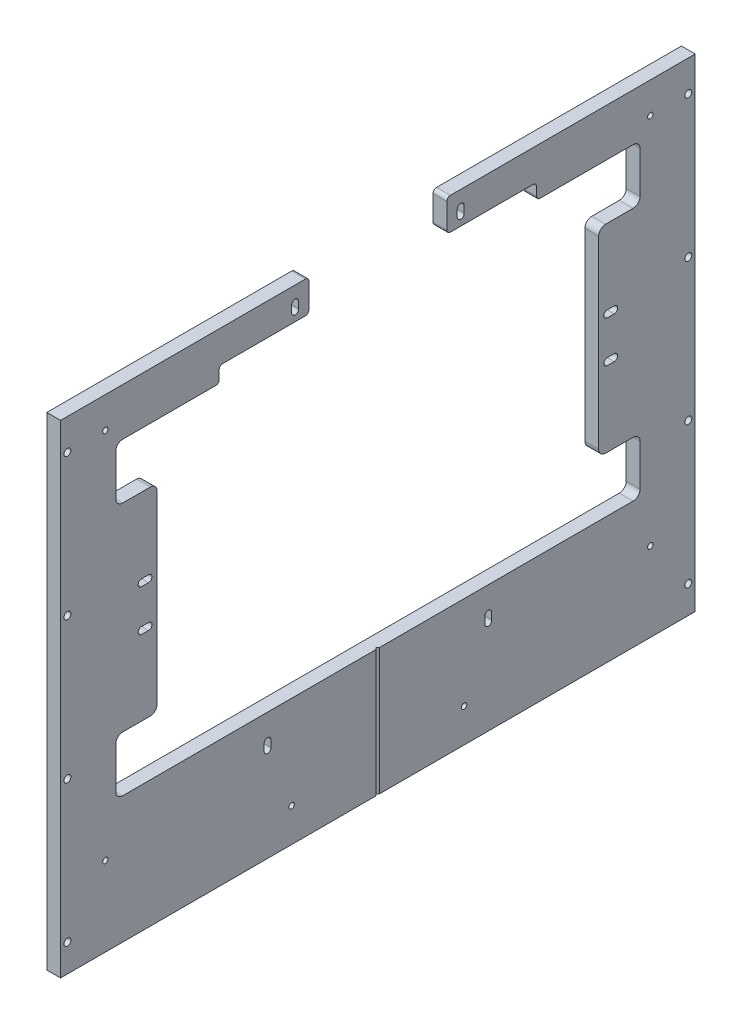
from build123d import *

# Parameters (mm, degrees)
SKETCH1_W                 = 12.7
SKETCH1_H                 = 444.5
EXTRUDE1_DEPTH            = 292.1
EXTRUDE1_DEPTH_BACK       = 292.1
CUT_EXTRUDE1_REACH        = 14.7
CUT_EXTRUDE2_REACH        = 14.7
SKETCH5_W                 = 127
SKETCH5_H                 = 43.65625
FILLET2_R                 = 6.35
M6X1_0_TAPPED_HOLE1_D     = 5
M6X1_0_TAPPED_HOLE1_DEPTH = 12.7
SKETCH11_W                = 292.1
SKETCH11_H                = 14.2875
CUT_EXTRUDE3_DEPTH        = 13.7
FILLET3_R                 = 3.175
CUT_EXTRUDE8_REACH        = 14.7
CUT_EXTRUDE7_DEPTH        = 1
CUT_EXTRUDE7_DEPTH_BACK   = 445.5
M6X1_0_TAPPED_HOLE2_D     = 5
M6X1_0_TAPPED_HOLE2_DEPTH = 12.7
M6_CLEARANCE_HOLE1_D      = 6.4
M6_CLEARANCE_HOLE1_DEPTH  = 12.7
M6X1_0_TAPPED_HOLE3_D     = 5
M6X1_0_TAPPED_HOLE3_DEPTH = 12.7
CUT_EXTRUDE9_DEPTH        = 13.7


with BuildPart() as part:
    # Sketch1 → Extrude1 (new body, two sides)
    with BuildSketch(Plane.XY) as extrude1_sk:
        Rectangle(SKETCH1_W, SKETCH1_H)
    extrude(amount=EXTRUDE1_DEPTH)
    extrude(extrude1_sk.sketch, amount=-EXTRUDE1_DEPTH_BACK)

    # Sketch4 → Cut-Extrude1 (cut, up to next)
    with BuildSketch(Plane(origin=(6.35, 0, 0), x_dir=(0, 0, -1), z_dir=(1, 0, 0)), mode=Mode.PRIVATE) as cut_extrude1_sk1:
        Polygon((203.2, 127.79375), (241.3, 127.79375), (241.3, 178.59375), (-241.3, 178.59375), (-241.3, 127.79375), (-203.2, 127.79375), (-203.2, -54.76875), (-241.3, -54.76875), (-241.3, -105.56875), (241.3, -105.56875), (241.3, -54.76875), (203.2, -54.76875), align=None)
    cut_extrude1_tool1 = extrude(cut_extrude1_sk1.sketch, amount=-CUT_EXTRUDE1_REACH, mode=Mode.PRIVATE) & part.part
    add(cut_extrude1_tool1.solids().sort_by_distance((6.35, 36.5125, 0))[0], mode=Mode.SUBTRACT)

    # Sketch5 → Cut-Extrude2 (cut, up to next)
    with BuildSketch(Plane(origin=(6.35, 0, 0), x_dir=(0, 0, -1), z_dir=(1, 0, 0)), mode=Mode.PRIVATE) as cut_extrude2_sk1:
        with Locations((0, 200.421875)):
            Rectangle(SKETCH5_W, SKETCH5_H)
    cut_extrude2_tool1 = extrude(cut_extrude2_sk1.sketch, amount=-CUT_EXTRUDE2_REACH, mode=Mode.PRIVATE) & part.part
    add(cut_extrude2_tool1.solids().sort_by_distance((6.35, 200.421875, 0))[0], mode=Mode.SUBTRACT)

    # Fillet2
    fillet2_edges = [part.edges().sort_by_distance(p)[0] for p in [
        (0, 127.79375, -203.2),
        (0, -54.76875, -203.2),
        (0, -54.76875, -241.3),
        (0, -105.56875, -241.3),
        (0, -105.56875, 241.3),
        (0, -54.76875, 241.3),
        (0, -54.76875, 203.2),
        (0, 127.79375, 203.2),
        (0, 127.79375, 241.3),
        (0, 178.59375, 241.3),
        (0, 178.59375, -241.3),
        (0, 127.79375, -241.3),
    ]]
    fillet(fillet2_edges, radius=FILLET2_R)

    # M6x1.0 Tapped Hole1
    with Locations(Plane(origin=(6.35, 0, 0), x_dir=(0, 0, -1), z_dir=(1, 0, 0))):
        with Locations((76.2, 204.7875), (-76.2, 204.7875), (101.6, -132.23875), (-101.6, -132.23875), (0, 204.7875)):
            Hole(M6X1_0_TAPPED_HOLE1_D / 2, depth=M6X1_0_TAPPED_HOLE1_DEPTH)

    # Sketch11 → Cut-Extrude3 (cut, through all)
    with BuildSketch(Plane(origin=(6.35, 0, 0), x_dir=(0, 0, -1), z_dir=(1, 0, 0))):
        with Locations((0, 185.7375)):
            Rectangle(SKETCH11_W, SKETCH11_H)
    extrude(amount=-CUT_EXTRUDE3_DEPTH, mode=Mode.SUBTRACT)

    # Fillet3
    fillet3_edges = [part.edges().sort_by_distance(p)[0] for p in [
        (0, 192.88125, 63.5),
        (0, 192.88125, -63.5),
        (0, 192.88125, 146.05),
        (0, 178.59375, -146.05),
        (0, 178.59375, 146.05),
        (0, 192.88125, -146.05),
        (0, 222.25, 63.5),
        (0, 222.25, -63.5),
    ]]
    fillet(fillet3_edges, radius=FILLET3_R)

    # Sketch19 → Cut-Extrude8 (cut, up to next)
    with BuildSketch(Plane(origin=(6.35, 0, 0), x_dir=(0, 0, -1), z_dir=(1, 0, 0)), mode=Mode.PRIVATE) as cut_extrude8_sk1:
        with BuildLine():
            Line((79.375, 207.9625), (79.375, 201.6125))
            ThreePointArc((79.375, 201.6125), (76.2, 198.4375), (73.025, 201.6125))
            Line((73.025, 201.6125), (73.025, 207.9625))
            ThreePointArc((73.025, 207.9625), (76.2, 211.1375), (79.375, 207.9625))
        make_face()
    cut_extrude8_tool1 = extrude(cut_extrude8_sk1.sketch, amount=-CUT_EXTRUDE8_REACH, mode=Mode.PRIVATE) & part.part
    add(cut_extrude8_tool1.solids().sort_by_distance((6.35, 204.7875, -76.2))[0], mode=Mode.SUBTRACT)
    # Sketch19 → Cut-Extrude8 (cut, up to next)
    with BuildSketch(Plane(origin=(6.35, 0, 0), x_dir=(0, 0, -1), z_dir=(1, 0, 0)), mode=Mode.PRIVATE) as cut_extrude8_sk2:
        with BuildLine():
            Line((-73.025, 207.9625), (-73.025, 201.6125))
            ThreePointArc((-73.025, 201.6125), (-76.2, 198.4375), (-79.375, 201.6125))
            Line((-79.375, 201.6125), (-79.375, 207.9625))
            ThreePointArc((-79.375, 207.9625), (-76.2, 211.1375), (-73.025, 207.9625))
        make_face()
    cut_extrude8_tool2 = extrude(cut_extrude8_sk2.sketch, amount=-CUT_EXTRUDE8_REACH, mode=Mode.PRIVATE) & part.part
    add(cut_extrude8_tool2.solids().sort_by_distance((6.35, 204.7875, 76.2))[0], mode=Mode.SUBTRACT)
    # Sketch19 → Cut-Extrude8 (cut, up to next)
    with BuildSketch(Plane(origin=(6.35, 0, 0), x_dir=(0, 0, -1), z_dir=(1, 0, 0)), mode=Mode.PRIVATE) as cut_extrude8_sk3:
        with BuildLine():
            Line((-98.425, -129.06375), (-98.425, -135.41375))
            ThreePointArc((-98.425, -135.41375), (-101.6, -138.58875), (-104.775, -135.41375))
            Line((-104.775, -135.41375), (-104.775, -129.06375))
            ThreePointArc((-104.775, -129.06375), (-101.6, -125.88875), (-98.425, -129.06375))
        make_face()
    cut_extrude8_tool3 = extrude(cut_extrude8_sk3.sketch, amount=-CUT_EXTRUDE8_REACH, mode=Mode.PRIVATE) & part.part
    add(cut_extrude8_tool3.solids().sort_by_distance((6.35, -132.23875, 101.6))[0], mode=Mode.SUBTRACT)
    # Sketch19 → Cut-Extrude8 (cut, up to next)
    with BuildSketch(Plane(origin=(6.35, 0, 0), x_dir=(0, 0, -1), z_dir=(1, 0, 0)), mode=Mode.PRIVATE) as cut_extrude8_sk4:
        with BuildLine():
            Line((104.775, -129.06375), (104.775, -135.41375))
            ThreePointArc((104.775, -135.41375), (101.6, -138.58875), (98.425, -135.41375))
            Line((98.425, -135.41375), (98.425, -129.06375))
            ThreePointArc((98.425, -129.06375), (101.6, -125.88875), (104.775, -129.06375))
        make_face()
    cut_extrude8_tool4 = extrude(cut_extrude8_sk4.sketch, amount=-CUT_EXTRUDE8_REACH, mode=Mode.PRIVATE) & part.part
    add(cut_extrude8_tool4.solids().sort_by_distance((6.35, -132.23875, -101.6))[0], mode=Mode.SUBTRACT)

    # Sketch18 → Cut-Extrude7 (cut, two sides)
    with BuildSketch(Plane.XZ.offset(222.25)) as cut_extrude7_sk:
        Polygon((6.35, 1.5875), (6.35, -1.5875), (4.7625, 0), align=None)
    extrude(amount=CUT_EXTRUDE7_DEPTH, mode=Mode.SUBTRACT)
    extrude(cut_extrude7_sk.sketch, amount=-CUT_EXTRUDE7_DEPTH_BACK, mode=Mode.SUBTRACT)

    # M6x1.0 Tapped Hole2
    with Locations(Plane(origin=(6.35, 0, 0), x_dir=(0, 0, -1), z_dir=(1, 0, 0))):
        with Locations((79.375, -191.29375), (-79.375, -191.29375), (250.825, -149.225), (250.825, 193.675), (-250.825, 193.675), (-250.825, -149.225)):
            Hole(M6X1_0_TAPPED_HOLE2_D / 2, depth=M6X1_0_TAPPED_HOLE2_DEPTH)

    # M6 Clearance Hole1
    with Locations(Plane(origin=(6.35, 0, 0), x_dir=(0, 0, -1), z_dir=(1, 0, 0))):
        with Locations((-285.75, -196.85), (-285.75, -66.675), (-285.75, 193.675), (-285.75, 63.5), (285.75, 193.675), (285.75, 63.5), (285.75, -66.675), (285.75, -196.85)):
            Hole(M6_CLEARANCE_HOLE1_D / 2, depth=M6_CLEARANCE_HOLE1_DEPTH)

    # M6x1.0 Tapped Hole3
    with Locations(Plane(origin=(6.35, 55.5625, 214.3125), x_dir=(0, 1, 0), z_dir=(1, 0, 0))):
        with Locations((0, 0), (-38.1, 0), (0, -428.625), (-38.1, -428.625)):
            Hole(M6X1_0_TAPPED_HOLE3_D / 2, depth=M6X1_0_TAPPED_HOLE3_DEPTH)

    # Sketch28 → Cut-Extrude9 (cut, through all)
    with BuildSketch(Plane(origin=(6.35, 0, 0), x_dir=(0, 0, -1), z_dir=(1, 0, 0))):
        with BuildLine():
            Line((-217.4875, 20.6375), (-211.1375, 20.6375))
            ThreePointArc((-211.1375, 20.6375), (-207.9625, 17.4625), (-211.1375, 14.2875))
            Line((-211.1375, 14.2875), (-217.4875, 14.2875))
            ThreePointArc((-217.4875, 14.2875), (-220.6625, 17.4625), (-217.4875, 20.6375))
        make_face()
        with BuildLine():
            Line((-217.4875, 58.7375), (-211.1375, 58.7375))
            ThreePointArc((-211.1375, 58.7375), (-207.9625, 55.5625), (-211.1375, 52.3875))
            Line((-211.1375, 52.3875), (-217.4875, 52.3875))
            ThreePointArc((-217.4875, 52.3875), (-220.6625, 55.5625), (-217.4875, 58.7375))
        make_face()
        with BuildLine():
            Line((-73.025, 201.6125), (-73.025, 207.9625))
            ThreePointArc((-73.025, 207.9625), (-76.2, 211.1375), (-79.375, 207.9625))
            Line((-79.375, 207.9625), (-79.375, 201.6125))
            ThreePointArc((-79.375, 201.6125), (-76.2, 198.4375), (-73.025, 201.6125))
        make_face()
        with BuildLine():
            Line((79.375, 201.6125), (79.375, 207.9625))
            ThreePointArc((79.375, 207.9625), (76.2, 211.1375), (73.025, 207.9625))
            Line((73.025, 207.9625), (73.025, 201.6125))
            ThreePointArc((73.025, 201.6125), (76.2, 198.4375), (79.375, 201.6125))
        make_face()
        with BuildLine():
            Line((104.775, -135.41375), (104.775, -129.06375))
            ThreePointArc((104.775, -129.06375), (101.6, -125.88875), (98.425, -129.06375))
            Line((98.425, -129.06375), (98.425, -135.41375))
            ThreePointArc((98.425, -135.41375), (101.6, -138.58875), (104.775, -135.41375))
        make_face()
        with BuildLine():
            Line((-98.425, -135.41375), (-98.425, -129.06375))
            ThreePointArc((-98.425, -129.06375), (-101.6, -125.88875), (-104.775, -129.06375))
            Line((-104.775, -129.06375), (-104.775, -135.41375))
            ThreePointArc((-104.775, -135.41375), (-101.6, -138.58875), (-98.425, -135.41375))
        make_face()
        with BuildLine():
            Line((211.1375, 58.7375), (217.4875, 58.7375))
            ThreePointArc((217.4875, 58.7375), (220.6625, 55.5625), (217.4875, 52.3875))
            Line((217.4875, 52.3875), (211.1375, 52.3875))
            ThreePointArc((211.1375, 52.3875), (207.9625, 55.5625), (211.1375, 58.7375))
        make_face()
        with BuildLine():
            Line((211.1375, 20.6375), (217.4875, 20.6375))
            ThreePointArc((217.4875, 20.6375), (220.6625, 17.4625), (217.4875, 14.2875))
            Line((217.4875, 14.2875), (211.1375, 14.2875))
            ThreePointArc((211.1375, 14.2875), (207.9625, 17.4625), (211.1375, 20.6375))
        make_face()
    extrude(amount=-CUT_EXTRUDE9_DEPTH, mode=Mode.SUBTRACT)


solid = part.part
